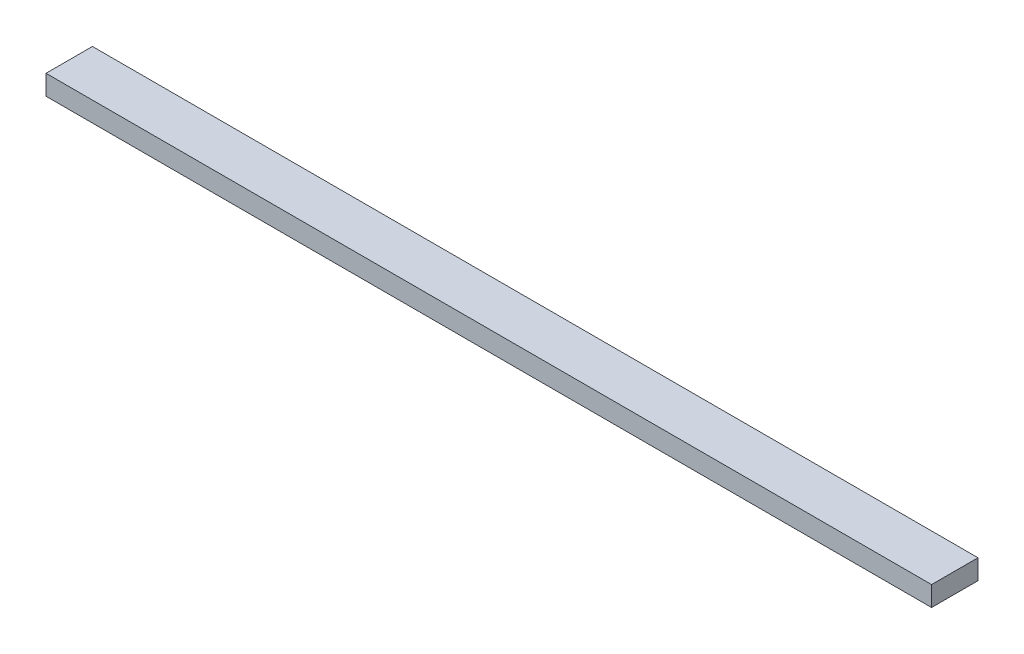
from build123d import *

# Parameters (mm, degrees)
SKETCH1_W           = 1695.45
SKETCH1_H           = 88.9
BOSS_EXTRUDE1_DEPTH = 38.1


with BuildPart() as part:
    # Sketch1 → Boss-Extrude1 (new body)
    with BuildSketch(Plane(origin=(0, 0, 0), x_dir=(1, 0, 0), z_dir=(0, 1, 0))):
        with Locations((847.725, 44.45)):
            Rectangle(SKETCH1_W, SKETCH1_H)
    extrude(amount=BOSS_EXTRUDE1_DEPTH)


solid = part.part
